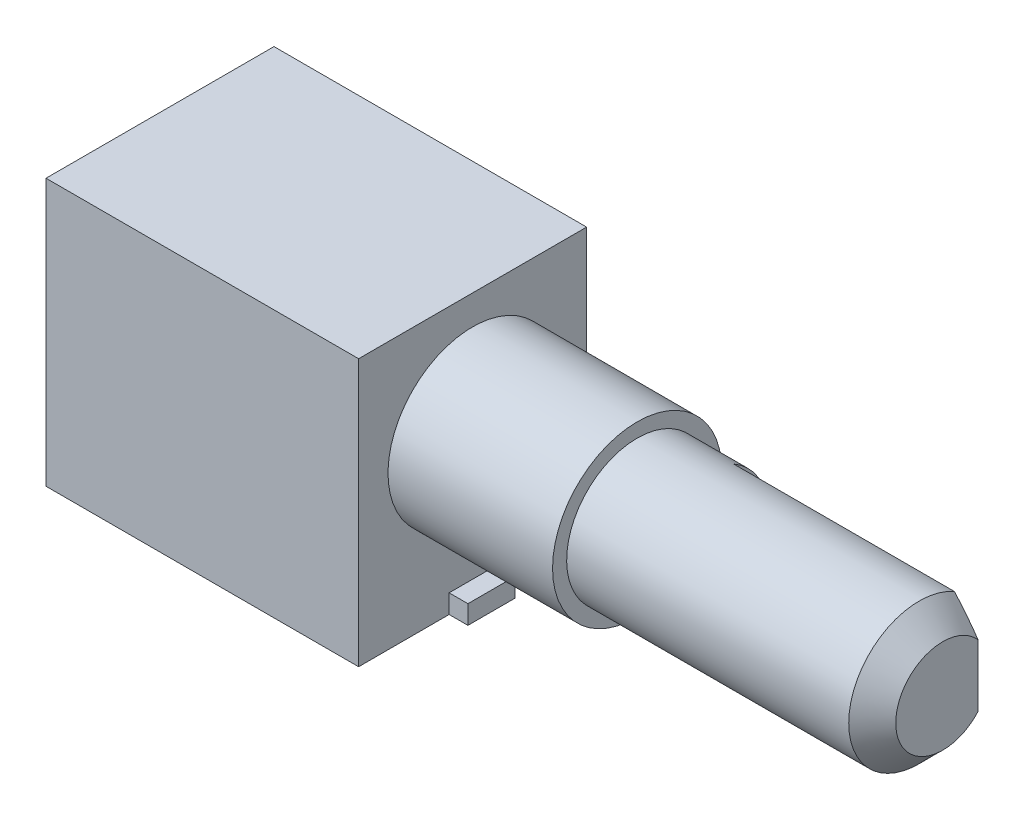
from build123d import *

# Parameters (mm, degrees)
SKETCH1_W           = 13.3
SKETCH1_H           = 11.35
BOSS_EXTRUDE1_DEPTH = 9.7
SKETCH2_R           = 3.6
BOSS_EXTRUDE2_DEPTH = 7
SKETCH3_R           = 3
BOSS_EXTRUDE4_DEPTH = 13
SKETCH4_W           = 2
SKETCH4_H           = 0.8
BOSS_EXTRUDE5_DEPTH = 0.8
SKETCH5_W           = 9.645805708
SKETCH5_H           = 9.062919638
CUT_EXTRUDE1_DEPTH  = 10.4
CHAMFER1_SIZE       = 1


with BuildPart() as part:
    # Sketch1 → Boss-Extrude1 (new body)
    with BuildSketch(Plane.XY):
        with Locations((6.65, 5.675)):
            Rectangle(SKETCH1_W, SKETCH1_H)
    extrude(amount=BOSS_EXTRUDE1_DEPTH)

    # Sketch2 → Boss-Extrude2 (add)
    with BuildSketch(Plane(origin=(13.3, 0, 0), x_dir=(0, 0, -1), z_dir=(1, 0, 0))):
        with Locations(Location((-4.85, 6.5, 0), (0, 0, 270))):  # turned: the seam where the file's is
            Circle(SKETCH2_R)
    extrude(amount=BOSS_EXTRUDE2_DEPTH)

    # Sketch3 → Boss-Extrude4 (add)
    with BuildSketch(Plane(origin=(20.3, 0, 0), x_dir=(0, 0, -1), z_dir=(1, 0, 0))):
        with Locations(Location((-4.85, 6.5, 0), (0, 0, 270))):  # turned: the seam where the file's is
            Circle(SKETCH3_R)
    extrude(amount=BOSS_EXTRUDE4_DEPTH)

    # Sketch4 → Boss-Extrude5 (add)
    with BuildSketch(Plane(origin=(13.3, 0, 0), x_dir=(0, 0, -1), z_dir=(1, 0, 0))):
        with Locations((-4.85, 0.4)):
            Rectangle(SKETCH4_W, SKETCH4_H)
    extrude(amount=BOSS_EXTRUDE5_DEPTH)

    # Sketch5 → Cut-Extrude1 (cut)
    with BuildSketch(Plane(origin=(33.3, 0, 0), x_dir=(0, 0, -1), z_dir=(1, 0, 0))):
        with Locations((1.472902854, 6.5)):
            Rectangle(SKETCH5_W, SKETCH5_H)
    extrude(amount=-CUT_EXTRUDE1_DEPTH, mode=Mode.SUBTRACT)

    # Chamfer1
    chamfer1_edges = [part.edges().sort_by_distance(p)[0] for p in [
        (33.3, 7.276457135, 7.747777479),
    ]]
    chamfer(chamfer1_edges, length=CHAMFER1_SIZE)


solid = part.part
